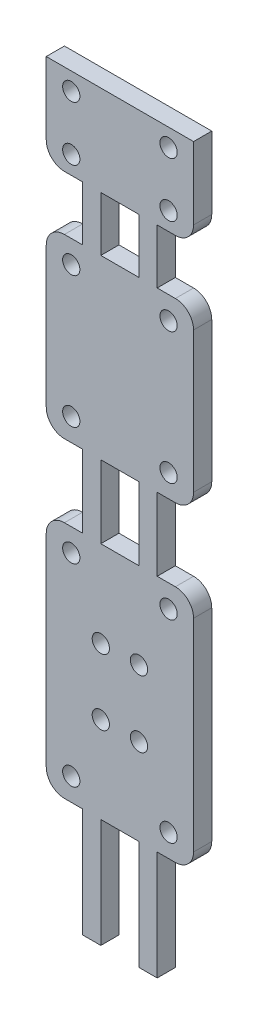
from build123d import *

# Parameters (mm, degrees)
SKETCH3_R           = 0.95
SKETCH3_W           = 4.2
SKETCH3_H           = 8
SKETCH3_H_2         = 6
BOSS_EXTRUDE3_DEPTH = 2


with BuildPart() as part:
    # Sketch3 → Boss-Extrude3 (new body)
    with BuildSketch(Plane.XY):
        with BuildLine():
            Line((0, 94.006448831), (0, 86.061448831))
            ThreePointArc((0, 86.061448831), (0.585786438, 84.647235269), (2, 84.061448831))
            Line((2, 84.061448831), (4, 84.061448831))
            Line((4, 84.061448831), (4, 78.061448831))
            Line((4, 78.061448831), (2, 78.061448831))
            ThreePointArc((2, 78.061448831), (0.585786438, 77.475662393), (0, 76.061448831))
            Line((0, 76.061448831), (0, 60.606448831))
            ThreePointArc((0, 60.606448831), (0.585786438, 59.192235269), (2, 58.606448831))
            Line((2, 58.606448831), (4, 58.606448831))
            Line((4, 58.606448831), (4, 50.606448831))
            Line((4, 50.606448831), (2, 50.606448831))
            ThreePointArc((2, 50.606448831), (0.585786438, 50.020662393), (0, 48.606448831))
            Line((0, 48.606448831), (0, 26.346448831))
            ThreePointArc((0, 26.346448831), (0.585786438, 24.932235269), (2, 24.346448831))
            Line((2, 24.346448831), (4, 24.346448831))
            Line((4, 24.346448831), (4, 12.346448831))
            Line((4, 12.346448831), (6, 12.346448831))
            Line((6, 12.346448831), (6, 24.346448831))
            Line((6, 24.346448831), (10.2, 24.346448831))
            Line((10.2, 24.346448831), (10.2, 12.346448831))
            Line((10.2, 12.346448831), (12.2, 12.346448831))
            Line((12.2, 12.346448831), (12.2, 24.346448831))
            Line((12.2, 24.346448831), (14.2, 24.346448831))
            ThreePointArc((14.2, 24.346448831), (15.614213562, 24.932235269), (16.2, 26.346448831))
            Line((16.2, 26.346448831), (16.2, 48.606448831))
            ThreePointArc((16.2, 48.606448831), (15.614213562, 50.020662393), (14.2, 50.606448831))
            Line((14.2, 50.606448831), (12.2, 50.606448831))
            Line((12.2, 50.606448831), (12.2, 58.606448831))
            Line((12.2, 58.606448831), (14.2, 58.606448831))
            ThreePointArc((14.2, 58.606448831), (15.614213562, 59.192235269), (16.2, 60.606448831))
            Line((16.2, 60.606448831), (16.2, 76.061448831))
            ThreePointArc((16.2, 76.061448831), (15.614213562, 77.475662393), (14.2, 78.061448831))
            Line((14.2, 78.061448831), (12.2, 78.061448831))
            Line((12.2, 78.061448831), (12.2, 84.061448831))
            Line((12.2, 84.061448831), (14.2, 84.061448831))
            ThreePointArc((14.2, 84.061448831), (15.614213562, 84.647235269), (16.2, 86.061448831))
            Line((16.2, 86.061448831), (16.2, 94.006448831))
            Line((16.2, 94.006448831), (0, 94.006448831))
        make_face()
        with Locations((6, 33.846448831)):
            Circle(SKETCH3_R, mode=Mode.SUBTRACT)
        with Locations((10.2, 33.846448831)):
            Circle(SKETCH3_R, mode=Mode.SUBTRACT)
        with Locations((2.75, 86.061448831)):
            Circle(SKETCH3_R, mode=Mode.SUBTRACT)
        with Locations((10.2, 41.166448831)):
            Circle(SKETCH3_R, mode=Mode.SUBTRACT)
        with Locations((13.45, 48.106448831)):
            Circle(SKETCH3_R, mode=Mode.SUBTRACT)
        with Locations((2.75, 92.061448831)):
            Circle(SKETCH3_R, mode=Mode.SUBTRACT)
        with Locations((13.45, 86.061448831)):
            Circle(SKETCH3_R, mode=Mode.SUBTRACT)
        with Locations((2.75, 61.106448831)):
            Circle(SKETCH3_R, mode=Mode.SUBTRACT)
        with Locations((13.45, 61.106448831)):
            Circle(SKETCH3_R, mode=Mode.SUBTRACT)
        with Locations((2.75, 75.561448831)):
            Circle(SKETCH3_R, mode=Mode.SUBTRACT)
        with Locations((13.45, 26.846448831)):
            Circle(SKETCH3_R, mode=Mode.SUBTRACT)
        with Locations((13.45, 75.561448831)):
            Circle(SKETCH3_R, mode=Mode.SUBTRACT)
        with Locations((13.45, 92.061448831)):
            Circle(SKETCH3_R, mode=Mode.SUBTRACT)
        with Locations((2.75, 26.846448831)):
            Circle(SKETCH3_R, mode=Mode.SUBTRACT)
        with Locations((6, 41.106448831)):
            Circle(SKETCH3_R, mode=Mode.SUBTRACT)
        with Locations((2.75, 48.106448831)):
            Circle(SKETCH3_R, mode=Mode.SUBTRACT)
        with Locations((8.1, 54.606448831)):
            Rectangle(SKETCH3_W, SKETCH3_H, mode=Mode.SUBTRACT)
        with Locations((8.1, 81.061448831)):
            Rectangle(SKETCH3_W, SKETCH3_H_2, mode=Mode.SUBTRACT)
    extrude(amount=BOSS_EXTRUDE3_DEPTH)


solid = part.part
